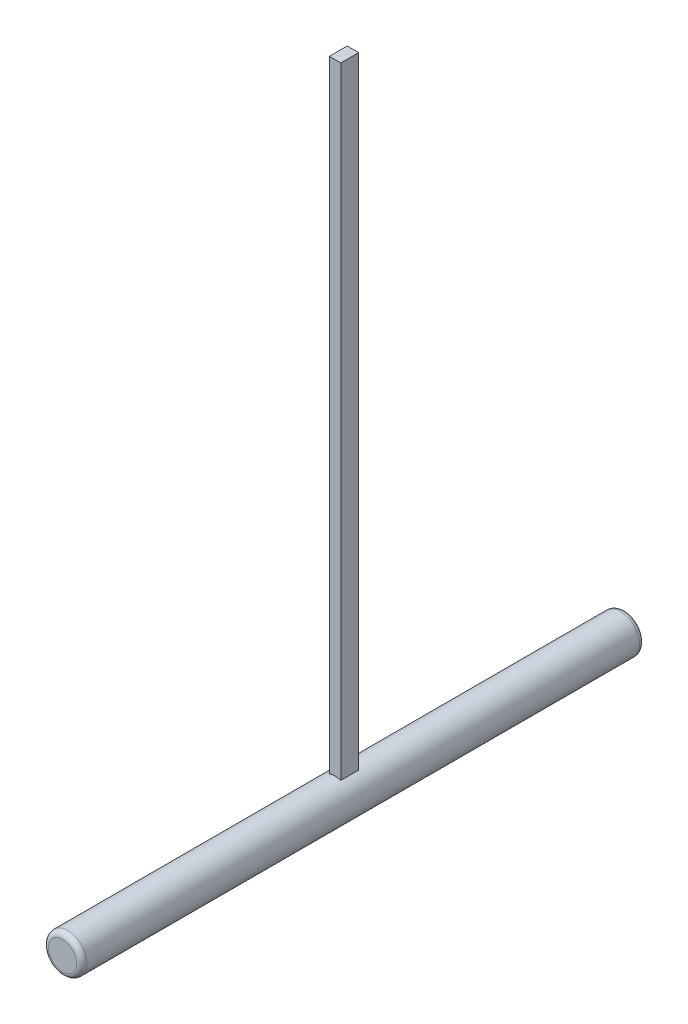
from build123d import *

# Parameters (mm, degrees)
SKETCH1_R           = 7.5
BOSS_EXTRUDE1_DEPTH = 220
FILLET1_R           = 2
BOSS_EXTRUDE2_REACH = 259.5
SKETCH3_W           = 4.49
SKETCH3_H           = 6.99


with BuildPart() as part:
    # Sketch1 → Boss-Extrude1 (new body)
    with BuildSketch(Plane.XY):
        Circle(SKETCH1_R)
    extrude(amount=BOSS_EXTRUDE1_DEPTH)

    # Fillet1
    fillet1_edges = [part.edges().sort_by_distance(p)[0] for p in [
        (-7.5, 0, 0),
        (-7.5, 0, 220),
    ]]
    fillet(fillet1_edges, radius=FILLET1_R)

    # Sketch3 → Boss-Extrude2 (add, up to next)
    with BuildSketch(Plane(origin=(0, 250, 0), x_dir=(1, 0, 0), z_dir=(0, 1, 0)), mode=Mode.PRIVATE) as boss_extrude2_sk1:
        with Locations((0, -110)):
            Rectangle(SKETCH3_W, SKETCH3_H)
    boss_extrude2_tool1 = extrude(boss_extrude2_sk1.sketch, amount=-BOSS_EXTRUDE2_REACH, mode=Mode.PRIVATE) - part.part
    add(boss_extrude2_tool1.solids().sort_by_distance((0, 250, 110))[0])


solid = part.part
